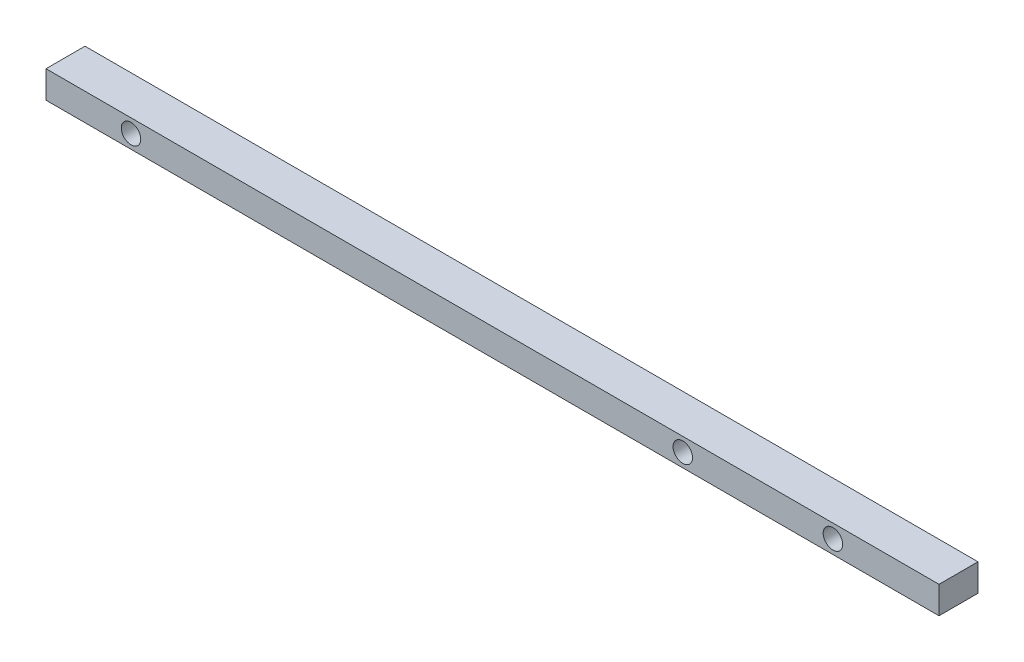
from build123d import *

# Parameters (mm, degrees)
SKETCH5_W           = 2.54
SKETCH5_H           = 1.778
BOSS_EXTRUDE3_DEPTH = 58.166
SKETCH6_R           = 0.635
CUT_EXTRUDE3_DEPTH  = 3.54
SKETCH8_R           = 0.635
CUT_EXTRUDE4_DEPTH  = 3.54


with BuildPart() as part:
    # Sketch5 → Boss-Extrude3 (new body)
    with BuildSketch(Plane(origin=(0, 0, 0), x_dir=(0, 0, -1), z_dir=(1, 0, 0))):
        with Locations((1.27, 0.889)):
            Rectangle(SKETCH5_W, SKETCH5_H)
    extrude(amount=BOSS_EXTRUDE3_DEPTH)

    # Sketch6 → Cut-Extrude3 (cut, through all)
    with BuildSketch(Plane.XY):
        with Locations((5.5372, 0.889)):
            Circle(SKETCH6_R)
    extrude(amount=-CUT_EXTRUDE3_DEPTH, mode=Mode.SUBTRACT)

    # Sketch8 → Cut-Extrude4 (cut, through all)
    with BuildSketch(Plane.XY):
        with Locations((41.4782, 0.889)):
            Circle(SKETCH8_R)
        with Locations((51.2572, 0.889)):
            Circle(SKETCH8_R)
    extrude(amount=-CUT_EXTRUDE4_DEPTH, mode=Mode.SUBTRACT)


solid = part.part
